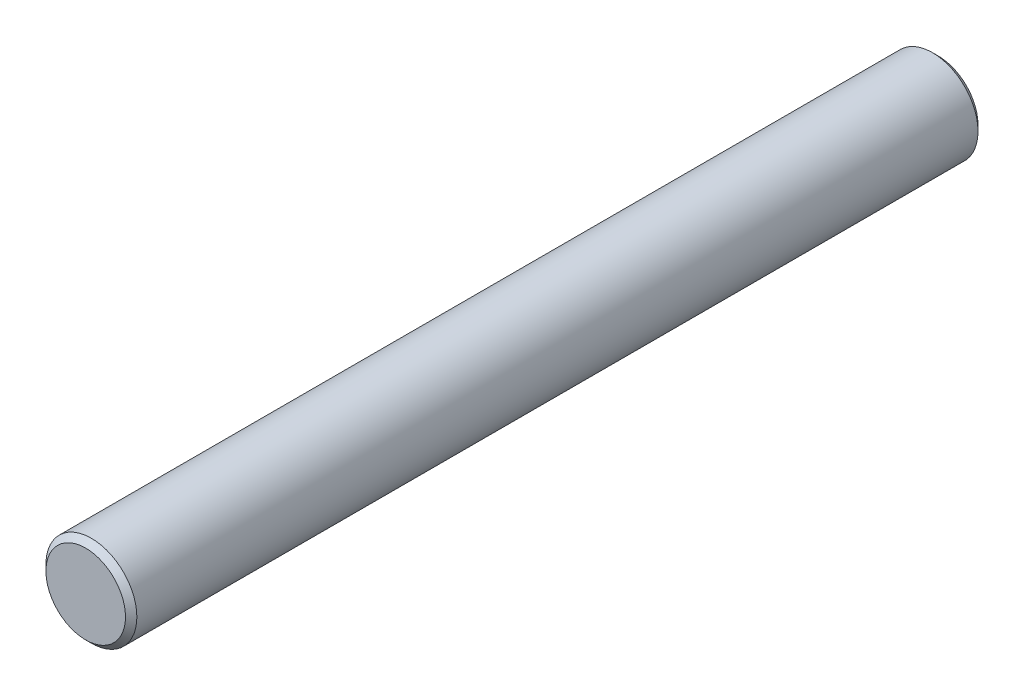
from build123d import *

# Parameters (mm, degrees)
SKETCH1_R           = 4
BOSS_EXTRUDE1_DEPTH = 75
CHAMFER1_SIZE       = 0.5


with BuildPart() as part:
    # Sketch1 → Boss-Extrude1 (new body)
    with BuildSketch(Plane.XY):
        Circle(SKETCH1_R)
    extrude(amount=BOSS_EXTRUDE1_DEPTH)

    # Chamfer1
    chamfer1_edges = [part.edges().sort_by_distance(p)[0] for p in [
        (-4, 0, 0),
        (-4, 0, 75),
    ]]
    chamfer(chamfer1_edges, length=CHAMFER1_SIZE)


solid = part.part
